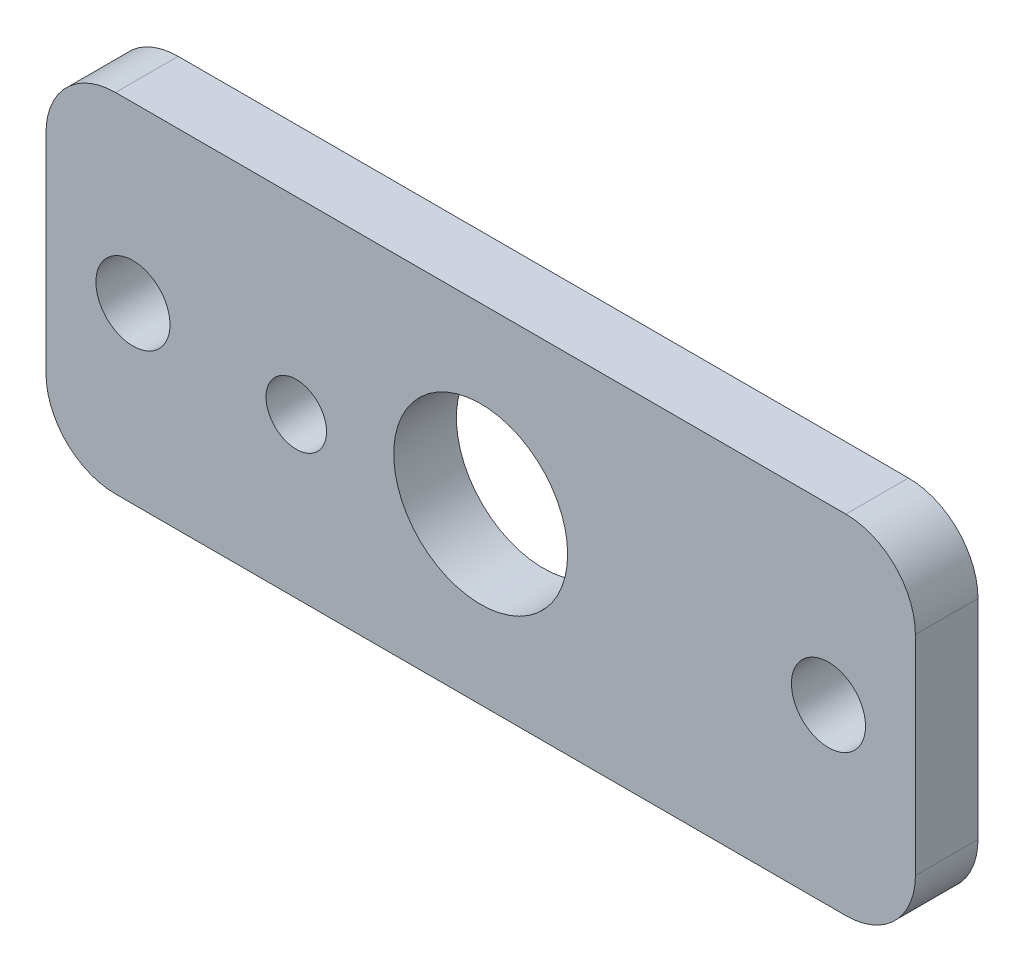
from build123d import *

# Parameters (mm, degrees)
SKETCH1_W             = 31.75
SKETCH1_H             = 12.7
BOSS_EXTRUDE1_DEPTH   = 2.286
FILLET1_R             = 2.54
SKETCH2_R             = 3.175
SKETCH2_R_2           = 1.1049
CUT_EXTRUDE1_DEPTH    = 3.286
F_2_CLEARANCE_HOLE1_D = 2.7051


with BuildPart() as part:
    # Sketch1 → Boss-Extrude1 (new body)
    with BuildSketch(Plane.XY):
        with Locations((-1.87e-07, -166.116000205)):
            Rectangle(SKETCH1_W, SKETCH1_H)
    extrude(amount=BOSS_EXTRUDE1_DEPTH)

    # Fillet1
    fillet1_edges = [part.edges().sort_by_distance(p)[0] for p in [
        (15.874999813, -172.466000205, 1.143),
        (-15.875000187, -172.466000205, 1.143),
        (-15.875000187, -159.766000205, 1.143),
        (15.874999813, -159.766000205, 1.143),
    ]]
    fillet(fillet1_edges, radius=FILLET1_R)

    # Sketch2 → Cut-Extrude1 (cut, through all)
    with BuildSketch(Plane.XY.offset(2.286)):
        with Locations((-1.87e-07, -166.116000205)):
            Circle(SKETCH2_R)
        with Locations((-6.735572471, -166.64610111)):
            Circle(SKETCH2_R_2)
    extrude(amount=-CUT_EXTRUDE1_DEPTH, mode=Mode.SUBTRACT)

    # #2 Clearance Hole1 (through all)
    with Locations(Plane.XY.offset(2.286)):
        with Locations((12.699999906, -166.116000205), (-12.700000094, -166.116000205)):
            Hole(F_2_CLEARANCE_HOLE1_D / 2)


solid = part.part
